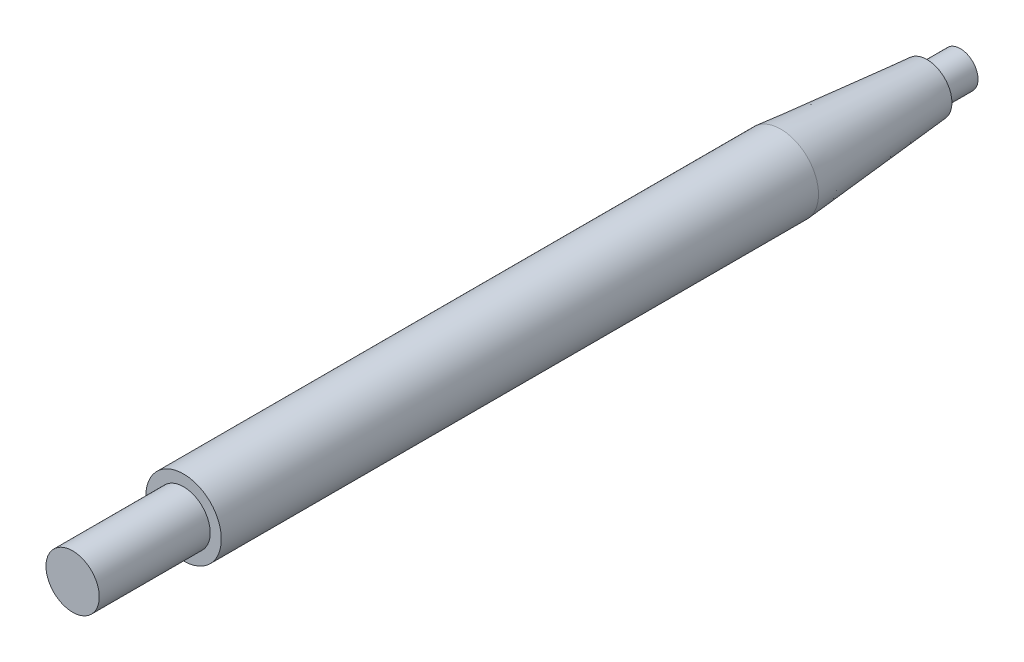
from build123d import *


with BuildPart() as part:
    # Base Sketch → Revolve1 (revolve)
    with BuildSketch(Plane(origin=(0, 0, 0), x_dir=(1, 0, 0), z_dir=(0, 1, 0))):
        Polygon((-11.225361683, 153.992599386), (-12.843485106, 153.992599386), (-12.843485106, 161.492599386), (-16.843485106, 161.492599386), (-16.843485106, -13.507400614), (-16.843485106, -38.507400614), (-10.843485106, -38.507400614), (-10.843485106, -13.507400614), (-8.343485106, -13.507400614), (-8.343485106, 121.052599386), align=None)
    revolve(axis=Axis((-16.843485106, 0, -161.492599386), (0, 0, 1)))


solid = part.part
